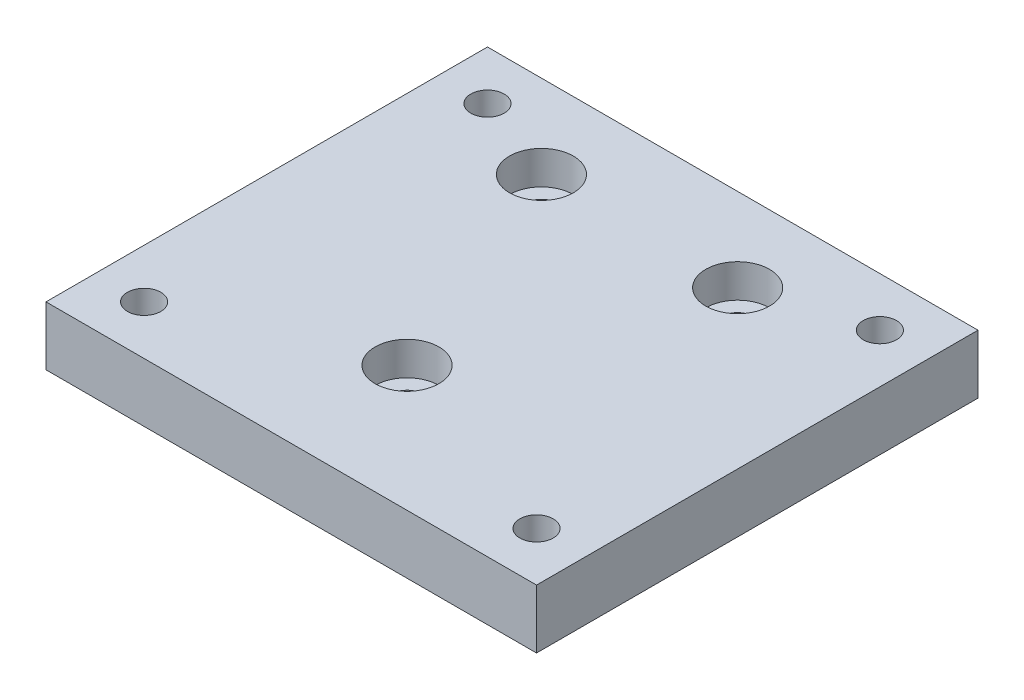
from build123d import *

# Parameters (mm, degrees)
SKETCH_1_W                   = 50
SKETCH_1_H                   = 45
EXTRUDE_1_DEPTH              = 6
HOLE_WIZARD_M3_1_D           = 3.4
HOLE_WIZARD_M3_1_CBORE_D     = 6.5
HOLE_WIZARD_M3_1_CBORE_DEPTH = 3.4
HOLE_WIZARD_M3_2_D           = 3.4
HOLE_WIZARD_M3_2_CBORE_D     = 6.5
HOLE_WIZARD_M3_2_CBORE_DEPTH = 3.4


with BuildPart() as part:
    # 草图1 → 凸台-拉伸1 (new body)
    with BuildSketch(Plane(origin=(0, 0, 0), x_dir=(1, 0, 0), z_dir=(0, 1, 0))):
        Rectangle(SKETCH_1_W, SKETCH_1_H)
    extrude(amount=EXTRUDE_1_DEPTH)

    # M3 六角凹头螺钉的柱形沉头孔1 (through all)
    with Locations(Plane(origin=(-20, 0, 17.5), x_dir=(0, 0, -1), z_dir=(0, -1, 0))):
        with Locations((0, 0), (0, 40), (35, 40), (35, 0)):
            CounterBoreHole(HOLE_WIZARD_M3_1_D / 2, HOLE_WIZARD_M3_1_CBORE_D / 2, HOLE_WIZARD_M3_1_CBORE_DEPTH)

    # M3 六角凹头螺钉的柱形沉头孔2 (through all)
    with Locations(Plane(origin=(-11, 6, -14), x_dir=(0, 0, 1), z_dir=(0, 1, 0))):
        with Locations((0, 0), (0, 20), (23.7, 10)):
            CounterBoreHole(HOLE_WIZARD_M3_2_D / 2, HOLE_WIZARD_M3_2_CBORE_D / 2, HOLE_WIZARD_M3_2_CBORE_DEPTH)


solid = part.part
